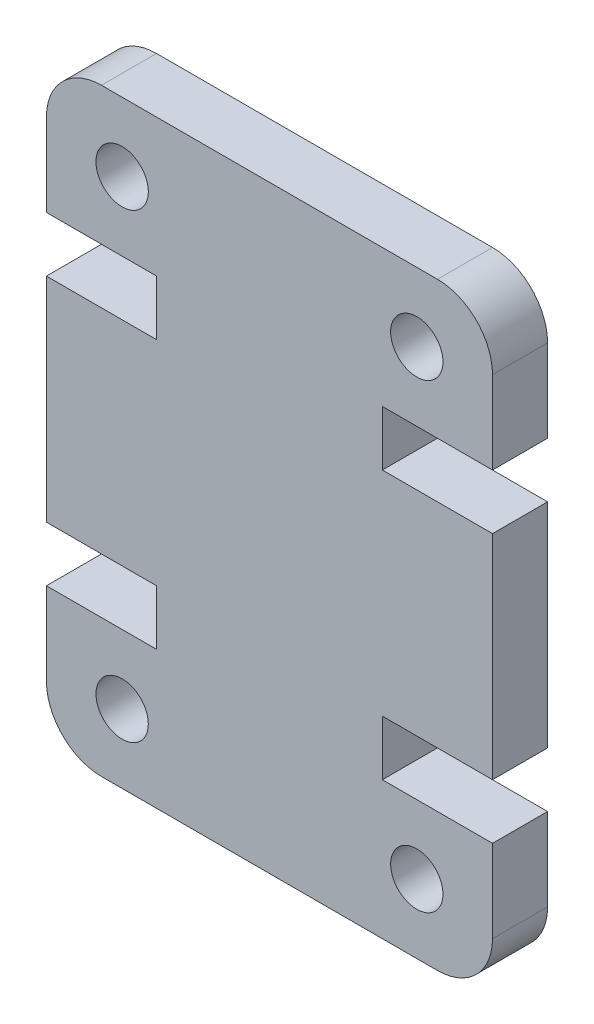
from build123d import *

# Parameters (mm, degrees)
SKETCH1_R           = 0.95
BOSS_EXTRUDE1_DEPTH = 4
SKETCH2_W           = 16.2
SKETCH2_H           = 21.74
CUT_EXTRUDE1_DEPTH  = 2


with BuildPart() as part:
    # Sketch1 → Boss-Extrude1 (new body)
    with BuildSketch(Plane.XY):
        with BuildLine():
            Line((0, 14.74), (0, 7))
            Line((0, 7), (4, 7))
            Line((4, 7), (4, 5))
            Line((4, 5), (0, 5))
            Line((0, 5), (0, 2))
            ThreePointArc((0, 2), (0.585786438, 0.585786438), (2, 0))
            Line((2, 0), (14.2, 0))
            ThreePointArc((14.2, 0), (15.614213562, 0.585786438), (16.2, 2))
            Line((16.2, 2), (16.2, 5))
            Line((16.2, 5), (12.2, 5))
            Line((12.2, 5), (12.2, 7))
            Line((12.2, 7), (16.2, 7))
            Line((16.2, 7), (16.2, 14.74))
            Line((16.2, 14.74), (12.2, 14.74))
            Line((12.2, 14.74), (12.2, 16.74))
            Line((12.2, 16.74), (16.2, 16.74))
            Line((16.2, 16.74), (16.2, 19.74))
            ThreePointArc((16.2, 19.74), (15.614213562, 21.154213562), (14.2, 21.74))
            Line((14.2, 21.74), (2, 21.74))
            ThreePointArc((2, 21.74), (0.585786438, 21.154213562), (0, 19.74))
            Line((0, 19.74), (0, 16.74))
            Line((0, 16.74), (4, 16.74))
            Line((4, 16.74), (4, 14.74))
            Line((4, 14.74), (0, 14.74))
        make_face()
        with Locations((13.45, 2.5)):
            Circle(SKETCH1_R, mode=Mode.SUBTRACT)
        with Locations((2.75, 19.24)):
            Circle(SKETCH1_R, mode=Mode.SUBTRACT)
        with Locations((2.75, 2.5)):
            Circle(SKETCH1_R, mode=Mode.SUBTRACT)
        with Locations((13.45, 19.24)):
            Circle(SKETCH1_R, mode=Mode.SUBTRACT)
    extrude(amount=BOSS_EXTRUDE1_DEPTH)

    # Sketch2 → Cut-Extrude1 (cut)
    with BuildSketch(Plane(origin=(0, 0, 0), x_dir=(-1, 0, 0), z_dir=(0, 0, -1))):
        with Locations((-8.1, 10.87)):
            Rectangle(SKETCH2_W, SKETCH2_H)
    extrude(amount=-CUT_EXTRUDE1_DEPTH, mode=Mode.SUBTRACT)


solid = part.part
